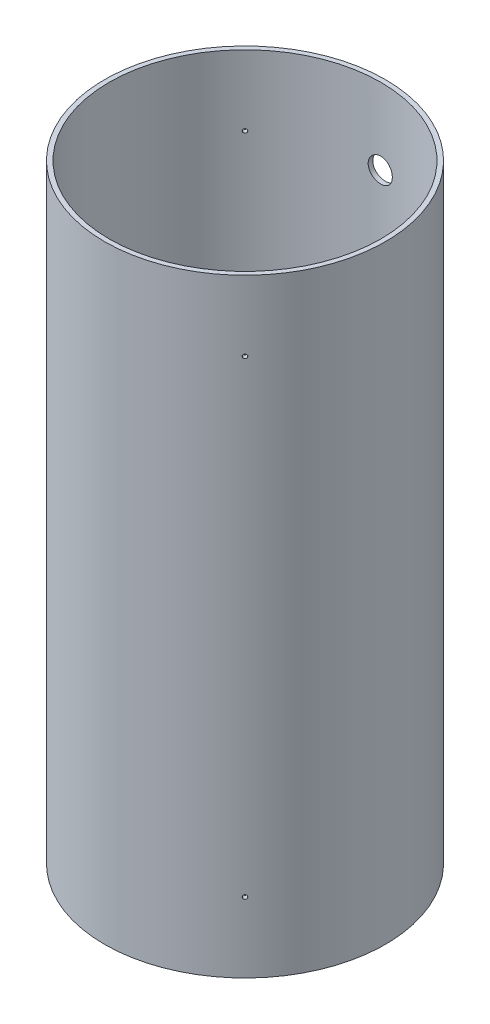
from build123d import *

# Parameters (mm, degrees)
SKETCH1_R           = 76.1746
SKETCH1_R_2         = 73.66
BOSS_EXTRUDE1_DEPTH = 330.2
SKETCH23_R          = 1.0922
SHEAR_SCRREWS_DEPTH = 108.72715257
CIRPATTERN1_COUNT   = 4


with BuildPart() as part:
    # Sketch1 → Boss-Extrude1 (new body)
    with BuildSketch(Plane(origin=(0, 0, 0), x_dir=(1, 0, 0), z_dir=(0, 1, 0))):
        Circle(SKETCH1_R)
        Circle(SKETCH1_R_2, mode=Mode.SUBTRACT)
    extrude(amount=BOSS_EXTRUDE1_DEPTH)

    # Sketch17 → 1/2 Clearance Hole5 (revolve, cut)
    with BuildSketch(Plane(origin=(0, 288.925, 0), x_dir=(0, -1, 0), z_dir=(1, 0, 0))):
        Polygon((0, 0), (0, 80.134507437), (6.54812, 76.2), (6.54812, 0), align=None)
    revolve(axis=Axis((0, 288.925, 6.35), (0, 0, -1)), mode=Mode.SUBTRACT)

    # Sketch21 → 1/2 Clearance Hole7 (revolve, cut)
    with BuildSketch(Plane(origin=(0, 41.275, 0), x_dir=(0, -1, 0), z_dir=(1, 0, 0))):
        Polygon((0, 0), (0, 80.134507437), (6.54812, 76.2), (6.54812, 0), align=None)
    revolve(axis=Axis((0, 41.275, 6.35), (0, 0, -1)), mode=Mode.SUBTRACT)

    # Sketch23 → Shear Scrrews (cut, through all)
    with BuildSketch(Plane(origin=(0, 0, 0), x_dir=(0.707106781, 0, 0.707106781), z_dir=(-0.707106781, 0, 0.707106781))):
        with Locations((0, 292.1)):
            Circle(SKETCH23_R)
        with Locations((0, 38.1)):
            Circle(SKETCH23_R)
    shear_scrrews = extrude(amount=-SHEAR_SCRREWS_DEPTH, mode=Mode.SUBTRACT)

    # CirPattern1: Shear Scrrews ×4 about axis
    cirpattern1_axis = Axis((0, 330.2, 0), (0, -1, 0))
    for i in range(1, CIRPATTERN1_COUNT):
        add(shear_scrrews.rotate(cirpattern1_axis, i * 360 / CIRPATTERN1_COUNT), mode=Mode.SUBTRACT)


solid = part.part
